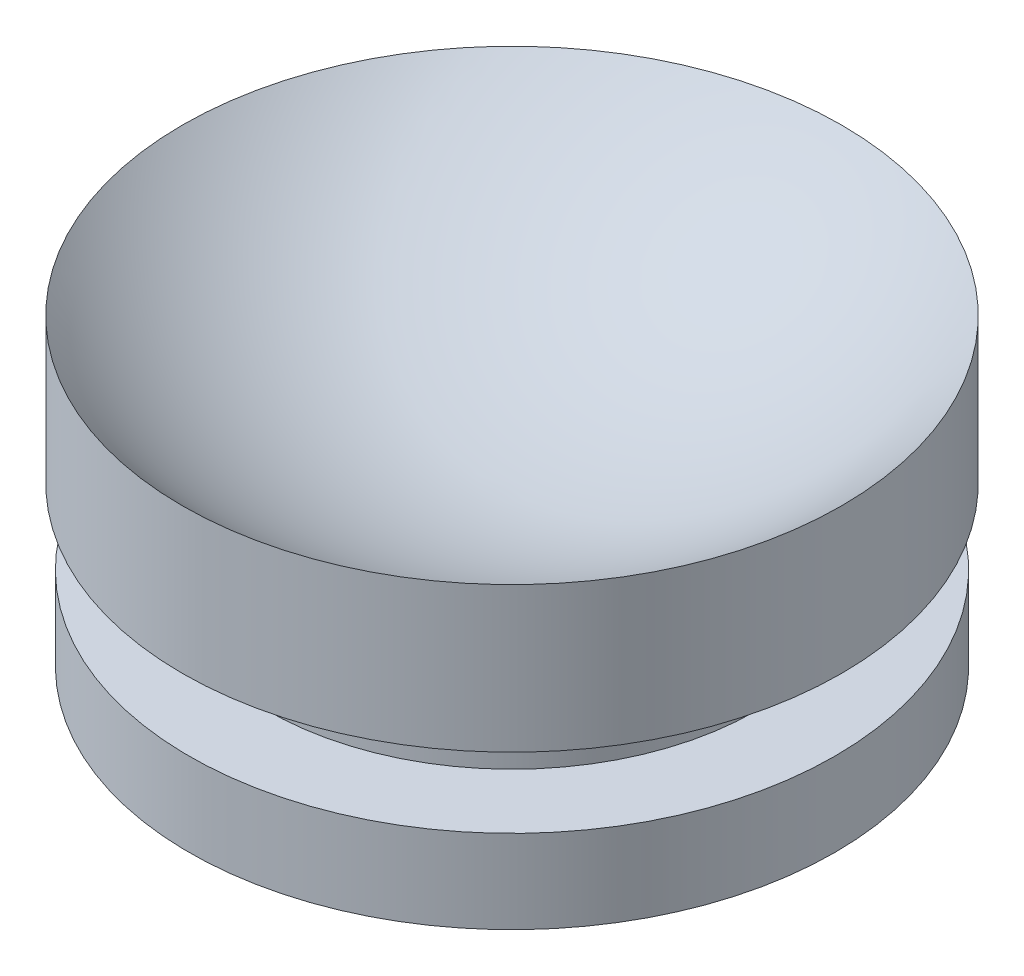
from build123d import *


with BuildPart() as part:
    # Sketch3 → Revolve3 (revolve)
    with BuildSketch(Plane.XY):
        with BuildLine():
            Line((0, 4.826), (0, 0))
            Line((0, 0), (9.831510881, 0))
            Line((9.831510881, 0), (9.831510881, 2.54))
            Line((9.831510881, 2.54), (7.440423316, 2.54))
            Line((7.440423316, 2.54), (7.440423316, 4.826))
            Line((7.440423316, 4.826), (10.038536816, 4.826))
            Line((10.038536816, 4.826), (10.038536816, 9.2456))
            ThreePointArc((10.038536816, 9.2456), (5.484183749, 5.979806298), (0, 4.826))
        make_face()
    revolve(axis=Axis((0, 0, 0), (0, 1, 0)))


solid = part.part
